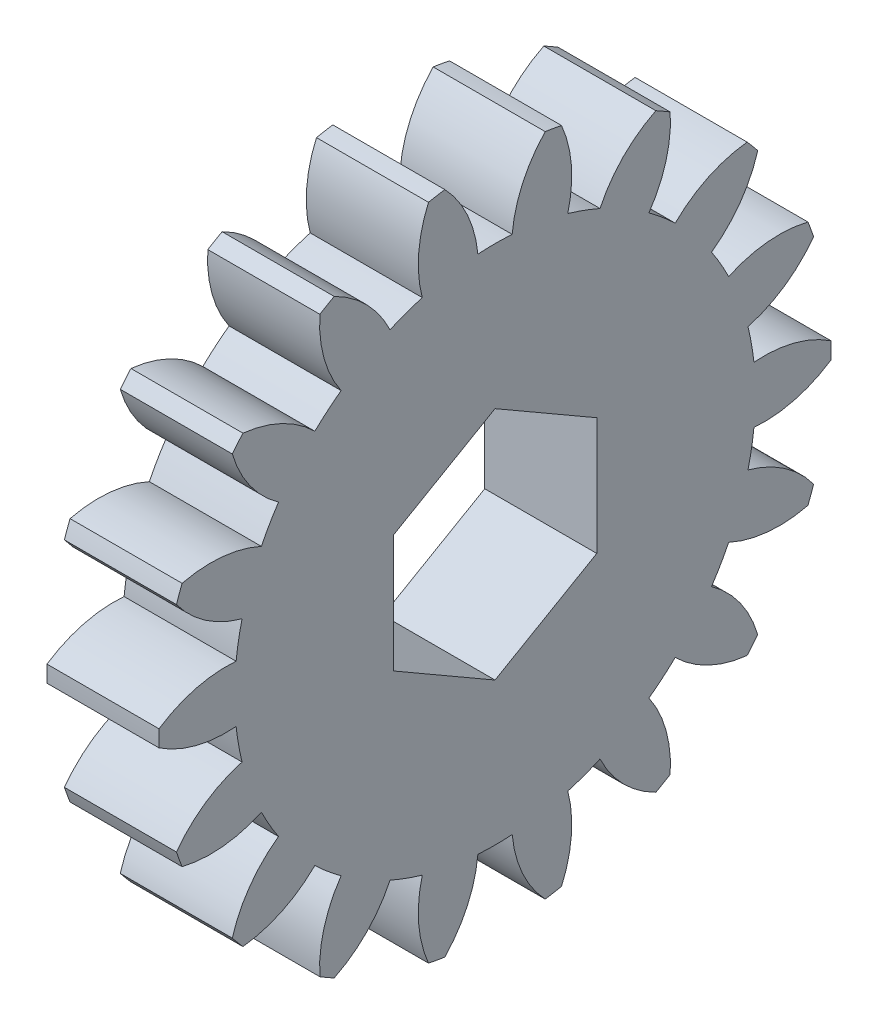
from build123d import *

# Parameters (mm, degrees)
BASPROSKE_W        = 3
BASPROSKE_H        = 9
TOOTHCUT_DEPTH     = 14.076696831
TEETHCUTS_COUNT    = 18
TEETHCUTS_ANGLE    = 340
CUT_EXTRUDE1_DEPTH = 14.007462246


with BuildPart() as part:
    # BasProSke → Base-Revolve (revolve)
    with BuildSketch(Plane(origin=(0, 0, 0), x_dir=(1, 0, 0), z_dir=(0, 1, 0)), mode=Mode.PRIVATE) as base_revolve_sk:
        with Locations((1.5, 4.5)):
            Rectangle(BASPROSKE_W, BASPROSKE_H)
    revolve(base_revolve_sk.sketch.rotate(Axis((-10, 0, 0), (1, 0, 0)), 180), axis=Axis((-10, 0, 0), (1, 0, 0)))

    # TooCutSke → ToothCut (cut, through all)
    with BuildSketch(Plane(origin=(0, 0, 0), x_dir=(0, 0, -1), z_dir=(1, 0, 0))):
        with BuildLine():
            ThreePointArc((0.45926649, 6.958861278), (0, 6.974), (-0.45926649, 6.958861278))
            ThreePointArc((-0.45926649, 6.958861278), (-0.743858876, 8.01799277), (-1.365479267, 8.921508366))
            ThreePointArc((-1.365479267, 8.921508366), (0, 9.0254), (1.365479267, 8.921508366))
            ThreePointArc((1.365479267, 8.921508366), (0.743858876, 8.01799277), (0.45926649, 6.958861278))
        make_face()
    toothcut = extrude(amount=TOOTHCUT_DEPTH, mode=Mode.SUBTRACT)

    # TeethCuts: ToothCut ×18 about axis
    teethcuts_axis = Axis((-10, 0, 0), (1, 0, 0))
    for i in range(1, TEETHCUTS_COUNT):
        add(toothcut.rotate(teethcuts_axis, i * TEETHCUTS_ANGLE / (TEETHCUTS_COUNT - 1)), mode=Mode.SUBTRACT)

    # Sketch1 → Cut-Extrude1 (cut, through all)
    with BuildSketch(Plane(origin=(3, 0, 0), x_dir=(0, 0, -1), z_dir=(1, 0, 0))):
        Polygon((0, 3.146558967), (-2.725, 1.573279484), (-2.725, -1.573279484), (0, -3.146558967), (2.725, -1.573279484), (2.725, 1.573279484), align=None)
    extrude(amount=-CUT_EXTRUDE1_DEPTH, mode=Mode.SUBTRACT)


solid = part.part
